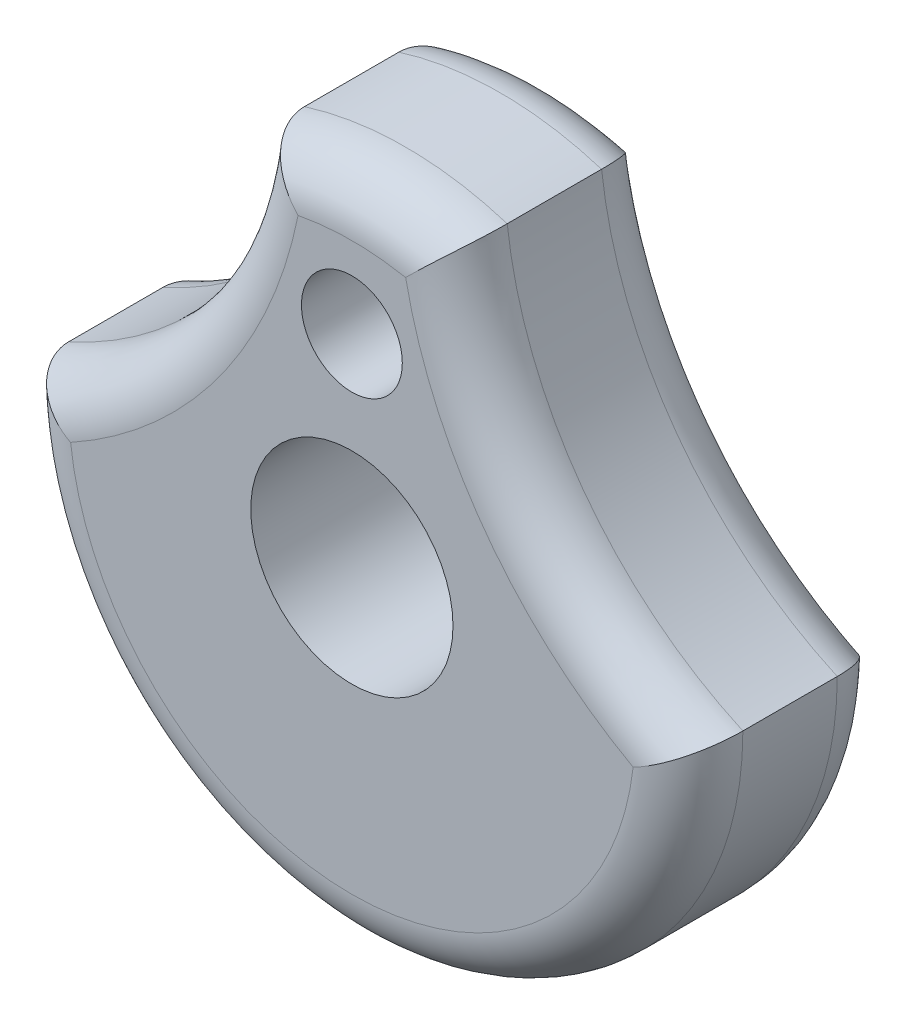
from build123d import *

# Parameters (mm, degrees)
SKETCH1_R           = 15.875
BOSS_EXTRUDE1_DEPTH = 9.525
SKETCH2_R           = 4.7625
CUT_EXTRUDE1_DEPTH  = 18.415
SKETCH3_R           = 2.3749
CUT_EXTRUDE2_DEPTH  = 18.415
CUT_EXTRUDE4_DEPTH  = 18.415
FILLET1_R           = 2.54
FILLET2_R           = 2.54


with BuildPart() as part:
    # Sketch1 → Boss-Extrude1 (new body)
    with BuildSketch(Plane.XY):
        with Locations(Location((0, 0, 0), (0, 0, 180))):
            Circle(SKETCH1_R)
    extrude(amount=BOSS_EXTRUDE1_DEPTH)

    # Sketch2 → Cut-Extrude1 (cut)
    with BuildSketch(Plane.XY.offset(9.525)):
        Circle(SKETCH2_R)
    extrude(amount=-CUT_EXTRUDE1_DEPTH, mode=Mode.SUBTRACT)

    # Sketch3 → Cut-Extrude2 (cut)
    with BuildSketch(Plane.XY.offset(9.525)):
        with Locations((0, 9.525)):
            Circle(SKETCH3_R)
    extrude(amount=-CUT_EXTRUDE2_DEPTH, mode=Mode.SUBTRACT)

    # Sketch4 → Cut-Extrude4 (cut)
    with BuildSketch(Plane.XY.offset(9.525)):
        with BuildLine():
            ThreePointArc((15.875, 0), (8.330712377, 6.107698439), (4.7752, 15.139785004))
            add(Edge.make_bspline(
                [(15.875, 0), (15.343893693, 11.113048416), (4.7752, 15.139785004)],
                knots=[0, 0, 0, 1, 1, 1], degree=2))
        make_face()
        with BuildLine():
            ThreePointArc((-15.875, 0), (-8.330712377, 6.107698439), (-4.7752, 15.139785004))
            add(Edge.make_bspline(
                [(-15.875, 0), (-15.420791341, 10.994065045), (-4.7752, 15.139785004)],
                knots=[0, 0, 0, 1, 1, 1], degree=2))
        make_face()
    extrude(amount=-CUT_EXTRUDE4_DEPTH, mode=Mode.SUBTRACT)


with BuildPart() as cut_extrude4_kept_piece:
    # of the separate pieces the step leaves, the one the design keeps (cut_extrude4_pieces_kept)
    add(part.part.solids().sort_by_distance((4.7625, 0, 0))[0])

    # Fillet1
    fillet1_edges = [cut_extrude4_kept_piece.edges().sort_by_distance(p)[0] for p in [
        (0, -15.875, 9.525),
        (8.330712377, 6.107698439, 9.525),
        (0, 15.875, 9.525),
        (-8.330712377, 6.107698439, 9.525),
    ]]
    fillet(fillet1_edges, radius=FILLET1_R)

    # Fillet2
    fillet2_edges = [cut_extrude4_kept_piece.edges().sort_by_distance(p)[0] for p in [
        (0, 15.875, 0),
        (0, -15.875, 0),
        (-8.330712377, 6.107698439, 0),
        (8.330712377, 6.107698439, 0),
    ]]
    fillet(fillet2_edges, radius=FILLET2_R)


solid = cut_extrude4_kept_piece.part
